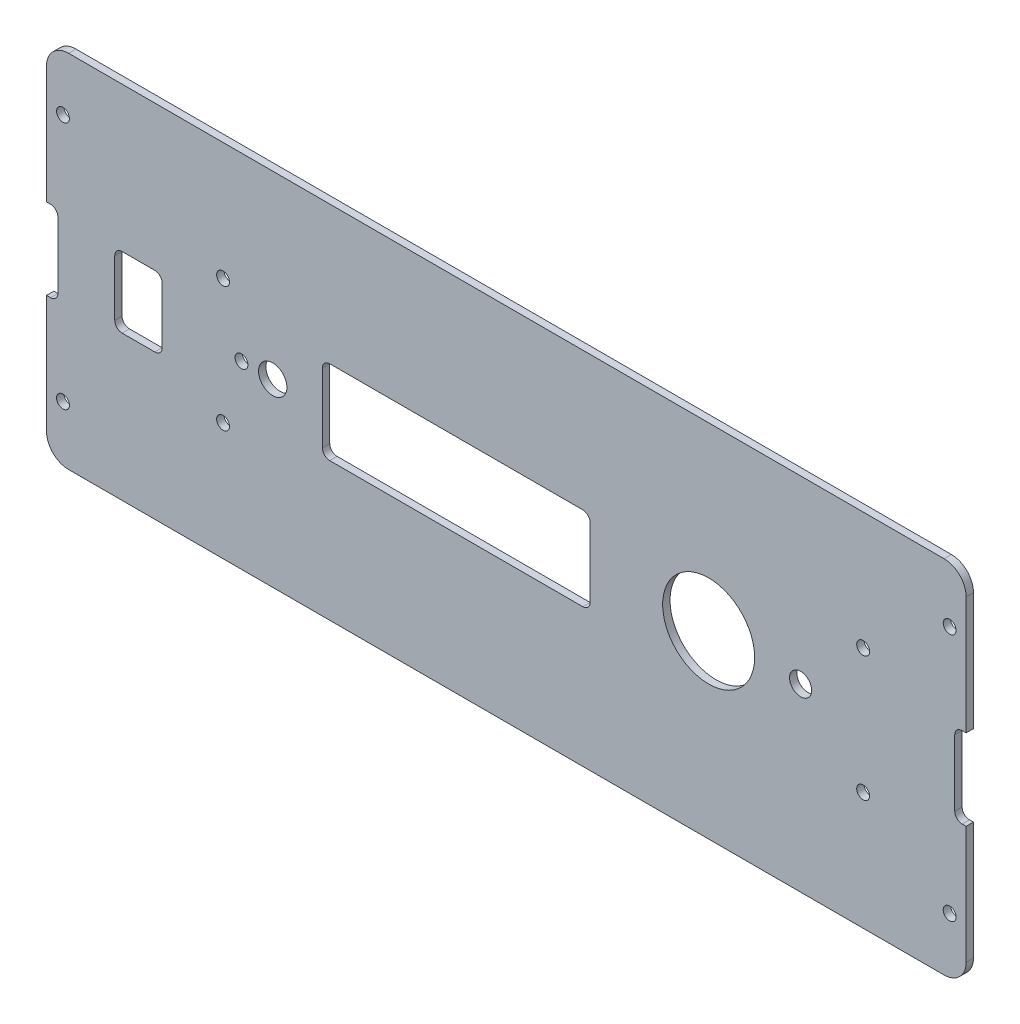
from build123d import *

# Parameters (mm, degrees)
SKETCH1_W                  = 250
SKETCH1_H                  = 98
BOSS_EXTRUDE1_DEPTH        = 2
FILLET1_R                  = 6
SKETCH2_W                  = 6.2
SKETCH2_H                  = 22
CUT_EXTRUDE1_DEPTH         = 12
FILLET2_R                  = 2
F_3_5_3_5_DIAMETER_HOLE1_D = 3.5
SKETCH6_R                  = 1.75
SKETCH6_R_2                = 3.855
SKETCH6_R_3                = 12.5
SKETCH6_R_4                = 3
SKETCH6_W                  = 72.8
SKETCH6_H                  = 22.8
SKETCH6_W_2                = 12.9
SKETCH6_H_2                = 19.2
CUT_EXTRUDE2_DEPTH         = 12
FILLET3_R                  = 2


with BuildPart() as part:
    # Sketch1 → Boss-Extrude1 (new body)
    with BuildSketch(Plane.XY):
        Rectangle(SKETCH1_W, SKETCH1_H)
    extrude(amount=BOSS_EXTRUDE1_DEPTH)

    # Fillet1
    fillet1_edges = [part.edges().sort_by_distance(p)[0] for p in [
        (-125, -49, 1),
        (125, -49, 1),
        (125, 49, 1),
        (-125, 49, 1),
    ]]
    fillet(fillet1_edges, radius=FILLET1_R)

    # Sketch2 → Cut-Extrude1 (cut)
    with BuildSketch(Plane.XY.offset(2)):
        with Locations((-125, 0)):
            Rectangle(SKETCH2_W, SKETCH2_H)
        with Locations((125, 0)):
            Rectangle(SKETCH2_W, SKETCH2_H)
    extrude(amount=-CUT_EXTRUDE1_DEPTH, mode=Mode.SUBTRACT)

    # Fillet2
    fillet2_edges = [part.edges().sort_by_distance(p)[0] for p in [
        (-121.9, 11, 1),
        (-121.9, -11, 1),
        (121.9, 11, 1),
        (121.9, -11, 1),
    ]]
    fillet(fillet2_edges, radius=FILLET2_R)

    # Ø3.5 (3.5) Diameter Hole1 (through all)
    with Locations(Plane.XY.offset(2)):
        with Locations((-120.52, 33.75), (-120.52, -33.75), (120.52, -33.75), (120.52, 33.75)):
            Hole(F_3_5_3_5_DIAMETER_HOLE1_D / 2)

    # Sketch6 → Cut-Extrude2 (cut)
    with BuildSketch(Plane.XY.offset(2)):
        with Locations((-77, 17)):
            Circle(SKETCH6_R)
        with Locations((-77, -17)):
            Circle(SKETCH6_R)
        with Locations((97, 17)):
            Circle(SKETCH6_R)
        with Locations((97, -17)):
            Circle(SKETCH6_R)
        with Locations((-72, 0)):
            Circle(SKETCH6_R)
        with Locations((-63.5, 0)):
            Circle(SKETCH6_R_2)
        with Locations((55, 0)):
            Circle(SKETCH6_R_3)
        with Locations((80, 0)):
            Circle(SKETCH6_R_4)
        with Locations((-13.6, 0)):
            Rectangle(SKETCH6_W, SKETCH6_H)
        with Locations((-100, 0)):
            Rectangle(SKETCH6_W_2, SKETCH6_H_2)
    extrude(amount=-CUT_EXTRUDE2_DEPTH, mode=Mode.SUBTRACT)

    # Fillet3
    fillet3_edges = [part.edges().sort_by_distance(p)[0] for p in [
        (22.8, 11.4, 1),
        (22.8, -11.4, 1),
        (-50, -11.4, 1),
        (-50, 11.4, 1),
        (-93.55, 9.6, 1),
        (-93.55, -9.6, 1),
        (-106.45, -9.6, 1),
        (-106.45, 9.6, 1),
    ]]
    fillet(fillet3_edges, radius=FILLET3_R)


solid = part.part
